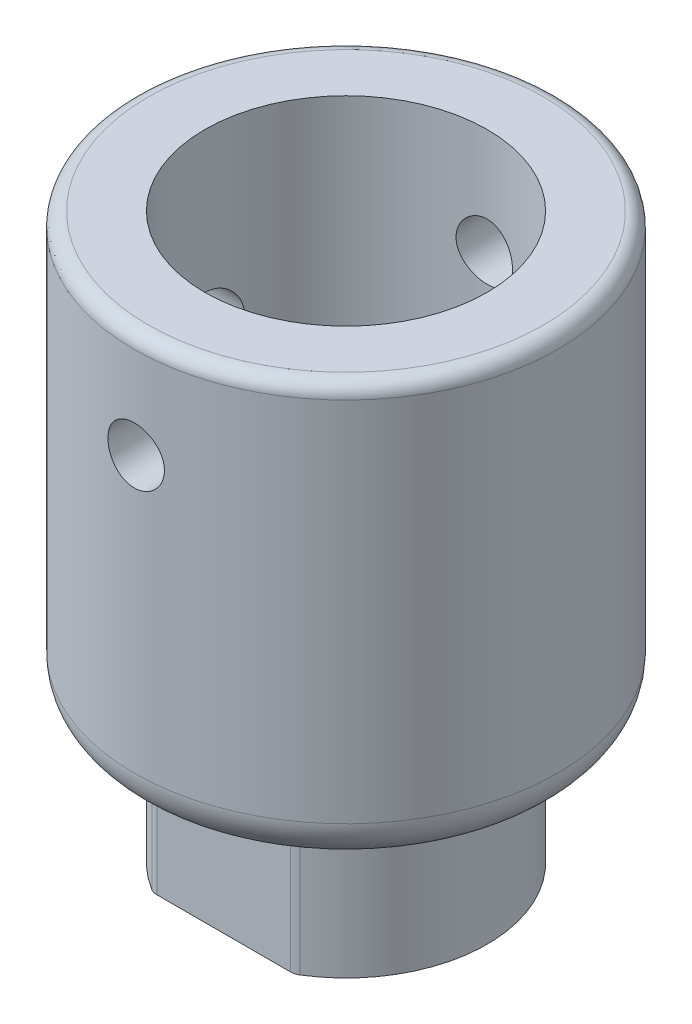
from build123d import *

# Parameters (mm, degrees)
ESBO_O1_R                  = 15
RESSALTO_EXTRUS_O1_DEPTH   = 30
ESBO_O2_R                  = 10
CORTE_EXTRUS_O1_DEPTH      = 15
RESSALTO_EXTRUS_O2_DEPTH   = 10
ESBO_O4_R                  = 1
CORTE_EXTRUS_O2_DEPTH      = 5
ESBO_O5_R                  = 3.5
CORTE_EXTRUS_O3_DEPTH      = 20
ESBO_O6_R                  = 2
CORTE_EXTRUS_O4_DEPTH      = 16
CORTE_EXTRUS_O4_DEPTH_BACK = 16
ESBO_O7_R                  = 2.5
CORTE_EXTRUS_O5_DEPTH      = 16.0000001
CORTE_EXTRUS_O6_DEPTH      = 4
FILETE1_R                  = 1
FILETE2_R                  = 3
FILETE4_R                  = 1


with BuildPart() as part:
    # Esboço1 → Ressalto-extrusão1 (new body)
    with BuildSketch(Plane(origin=(0, 0, 0), x_dir=(1, 0, 0), z_dir=(0, 1, 0))):
        Circle(ESBO_O1_R)
    extrude(amount=RESSALTO_EXTRUS_O1_DEPTH)

    # Esboço2 → Corte-extrusão1 (cut)
    with BuildSketch(Plane(origin=(0, 30, 0), x_dir=(1, 0, 0), z_dir=(0, 1, 0))):
        Circle(ESBO_O2_R)
    extrude(amount=-CORTE_EXTRUS_O1_DEPTH, mode=Mode.SUBTRACT)

    # Esboço3 → Ressalto-extrusão2 (add)
    with BuildSketch(Plane.XZ):
        with BuildLine():
            Line((-5, -8.660254038), (5, -8.660254038))
            ThreePointArc((5, -8.660254038), (10, 0), (5, 8.660254038))
            Line((5, 8.660254038), (-5, 8.660254038))
            ThreePointArc((-5, 8.660254038), (-10, 0), (-5, -8.660254038))
        make_face()
    extrude(amount=RESSALTO_EXTRUS_O2_DEPTH)

    # Esboço4 → Corte-extrusão2 (cut)
    with BuildSketch(Plane.XZ.offset(10)):
        Circle(ESBO_O4_R)
    extrude(amount=-CORTE_EXTRUS_O2_DEPTH, mode=Mode.SUBTRACT)

    # Esboço5 → Corte-extrusão3 (cut)
    with BuildSketch(Plane(origin=(0, 15, 0), x_dir=(1, 0, 0), z_dir=(0, 1, 0))):
        Circle(ESBO_O5_R)
    extrude(amount=-CORTE_EXTRUS_O3_DEPTH, mode=Mode.SUBTRACT)

    # Esboço6 → Corte-extrusão4 (cut, two sides)
    with BuildSketch(Plane.XY) as corte_extrus_o4_sk:
        with Locations((0, 22.5)):
            Circle(ESBO_O6_R)
    extrude(amount=CORTE_EXTRUS_O4_DEPTH, mode=Mode.SUBTRACT)
    extrude(corte_extrus_o4_sk.sketch, amount=-CORTE_EXTRUS_O4_DEPTH_BACK, mode=Mode.SUBTRACT)

    # Esboço7 → Corte-extrusão5 (cut, through all)
    with BuildSketch(Plane(origin=(0, 0, 0), x_dir=(0, 0, -1), z_dir=(1, 0, 0))):
        with Locations((0, 17.5)):
            Circle(ESBO_O7_R)
    extrude(amount=-CORTE_EXTRUS_O5_DEPTH, mode=Mode.SUBTRACT)

    # Esboço9 → Corte-extrusão6 (cut)
    with BuildSketch(Plane.XZ.offset(10)):
        with BuildLine():
            Line((2.645751311, 3), (2.645751311, -3))
            ThreePointArc((2.645751311, -3), (-4, 0), (2.645751311, 3))
        make_face()
    extrude(amount=-CORTE_EXTRUS_O6_DEPTH, mode=Mode.SUBTRACT)

    # Filete1
    filete1_edges = [part.edges().sort_by_distance(p)[0] for p in [
        (-15, 30, 0),
    ]]
    fillet(filete1_edges, radius=FILETE1_R)

    # Filete2
    filete2_edges = [part.edges().sort_by_distance(p)[0] for p in [
        (-15, 0, 0),
    ]]
    fillet(filete2_edges, radius=FILETE2_R)

    # Filete4
    filete4_edges = [part.edges().sort_by_distance(p)[0] for p in [
        (-5, -5, 8.660254038),
        (-5, -5, -8.660254038),
        (5, -5, -8.660254038),
        (5, -5, 8.660254038),
    ]]
    fillet(filete4_edges, radius=FILETE4_R)


solid = part.part
